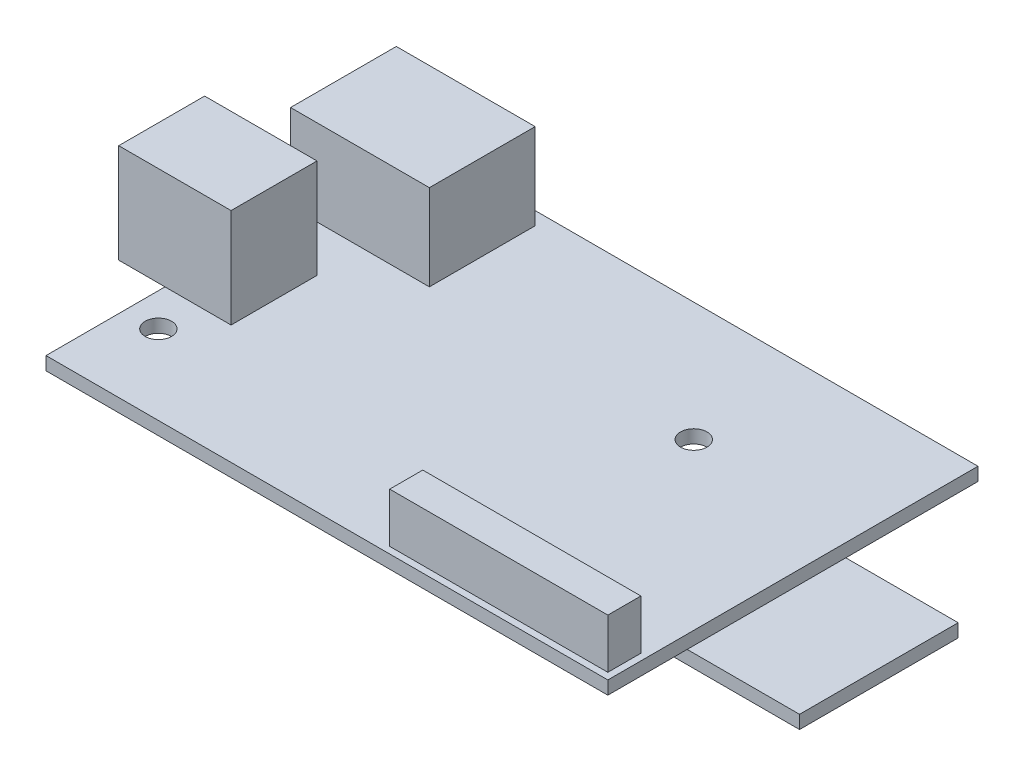
from build123d import *

# Parameters (mm, degrees)
SKETCH1_W           = 85
SKETCH1_H           = 56
BOSS_EXTRUDE1_DEPTH = 2
SKETCH2_W           = 21
SKETCH2_H           = 16
BOSS_EXTRUDE2_DEPTH = 13
SKETCH3_W           = 17
SKETCH3_H           = 13
BOSS_EXTRUDE3_DEPTH = 15
SKETCH4_W           = 33
SKETCH4_H           = 24
BOSS_EXTRUDE4_DEPTH = 2
CUT_EXTRUDE1_REACH  = 6
SKETCH5_R           = 2
SKETCH6_W           = 33
SKETCH6_H           = 5
BOSS_EXTRUDE5_DEPTH = 7.5


with BuildPart() as part:
    # Sketch1 → Boss-Extrude1 (new body)
    with BuildSketch(Plane(origin=(0, 0, 0), x_dir=(1, 0, 0), z_dir=(0, 1, 0))):
        with Locations((42.5, 28)):
            Rectangle(SKETCH1_W, SKETCH1_H)
    extrude(amount=BOSS_EXTRUDE1_DEPTH)

    # Sketch2 → Boss-Extrude2 (add)
    with BuildSketch(Plane(origin=(0, 2, 0), x_dir=(1, 0, 0), z_dir=(0, 1, 0))):
        with Locations((9.5, 46)):
            Rectangle(SKETCH2_W, SKETCH2_H)
    extrude(amount=BOSS_EXTRUDE2_DEPTH)

    # Sketch3 → Boss-Extrude3 (add)
    with BuildSketch(Plane(origin=(0, 2, 0), x_dir=(1, 0, 0), z_dir=(0, 1, 0))):
        with Locations((1.5, 24.5)):
            Rectangle(SKETCH3_W, SKETCH3_H)
    extrude(amount=BOSS_EXTRUDE3_DEPTH)

    # Sketch4 → Boss-Extrude4 (add)
    with BuildSketch(Plane.XZ):
        with Locations((85.5, -24)):
            Rectangle(SKETCH4_W, SKETCH4_H)
    extrude(amount=BOSS_EXTRUDE4_DEPTH)

    # Sketch5 → Cut-Extrude1 (cut, up to next)
    with BuildSketch(Plane(origin=(0, 2, 0), x_dir=(1, 0, 0), z_dir=(0, 1, 0)), mode=Mode.PRIVATE) as cut_extrude1_sk1:
        with Locations((5, 12)):
            Circle(SKETCH5_R)
    cut_extrude1_tool1 = extrude(cut_extrude1_sk1.sketch, amount=-CUT_EXTRUDE1_REACH, mode=Mode.PRIVATE) & part.part
    add(cut_extrude1_tool1.solids().sort_by_distance((5, 2, -12))[0], mode=Mode.SUBTRACT)
    # Sketch5 → Cut-Extrude1 (cut, up to next)
    with BuildSketch(Plane(origin=(0, 2, 0), x_dir=(1, 0, 0), z_dir=(0, 1, 0)), mode=Mode.PRIVATE) as cut_extrude1_sk2:
        with Locations((60, 38)):
            Circle(SKETCH5_R)
    cut_extrude1_tool2 = extrude(cut_extrude1_sk2.sketch, amount=-CUT_EXTRUDE1_REACH, mode=Mode.PRIVATE) & part.part
    add(cut_extrude1_tool2.solids().sort_by_distance((60, 2, -38))[0], mode=Mode.SUBTRACT)

    # Sketch6 → Boss-Extrude5 (add)
    with BuildSketch(Plane(origin=(0, 2, 0), x_dir=(1, 0, 0), z_dir=(0, 1, 0))):
        with Locations((67.5, 3.5)):
            Rectangle(SKETCH6_W, SKETCH6_H)
    extrude(amount=BOSS_EXTRUDE5_DEPTH)


solid = part.part
